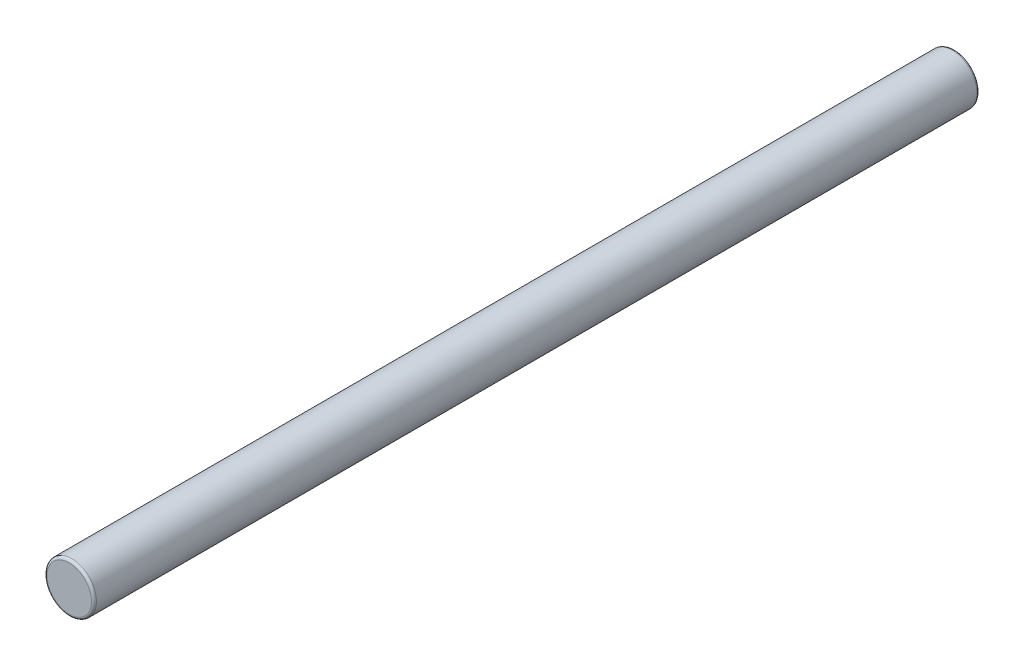
from build123d import *

# Parameters (mm, degrees)
SKETCH1_R           = 0.5
BOSS_EXTRUDE1_DEPTH = 8.95
FILLET1_R           = 0.05


with BuildPart() as part:
    # Sketch1 → Boss-Extrude1 (new body, symmetric)
    with BuildSketch(Plane.XY):
        Circle(SKETCH1_R)
    extrude(amount=BOSS_EXTRUDE1_DEPTH, both=True)

    # Fillet1
    fillet1_edges = [part.edges().sort_by_distance(p)[0] for p in [
        (-0.5, 0, -8.95),
        (-0.5, 0, 8.95),
    ]]
    fillet(fillet1_edges, radius=FILLET1_R)


solid = part.part
